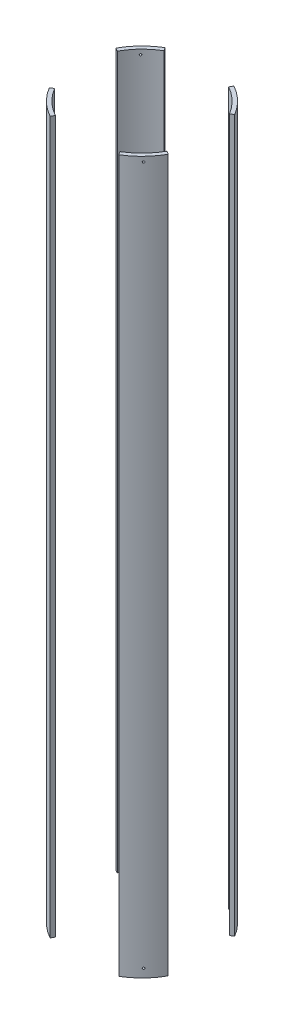
from build123d import *

# Parameters (mm, degrees)
SKETCH2_R               = 88.9
SKETCH2_R_2             = 83.82
BOSS_EXTRUDE1_DEPTH     = 467.94801
CUT_EXTRUDE1_DEPTH      = 468.94801
CUT_EXTRUDE1_DEPTH_BACK = 468.94801
SKETCH5_R               = 1.27
BOLT_HOLES_DEPTH        = 29.911624556
BOLT_PATTERN_COUNT      = 4


with BuildPart() as part:
    # Sketch2 → Boss-Extrude1 (new body, symmetric)
    with BuildSketch(Plane(origin=(0, 0, 0), x_dir=(1, 0, 0), z_dir=(0, 1, 0))):
        Circle(SKETCH2_R)
        Circle(SKETCH2_R_2, mode=Mode.SUBTRACT)
    extrude(amount=BOSS_EXTRUDE1_DEPTH, both=True)

    # Sketch3 → Cut-Extrude1 (cut, two sides)
    with BuildSketch(Plane(origin=(0, 0, 0), x_dir=(1, 0, 0), z_dir=(0, 1, 0))) as cut_extrude1_sk:
        Polygon((169.661755759, -94.300371224), (0, 0), (169.661755759, 101.677593364), align=None)
        Polygon((0, 0), (53.900027233, 96.974944394), (-58.116685864, 96.974944394), align=None)
        Polygon((-123.741299607, 68.777140945), (-123.741299607, -74.157652604), (0, 0), align=None)
        Polygon((-65.840936026, -118.45858783), (0, 0), (70.991745134, -118.45858783), align=None)
    extrude(amount=CUT_EXTRUDE1_DEPTH, mode=Mode.SUBTRACT)
    extrude(cut_extrude1_sk.sketch, amount=-CUT_EXTRUDE1_DEPTH_BACK, mode=Mode.SUBTRACT)

    # Sketch5 → Bolt holes (cut, through all)
    with BuildSketch(Plane(origin=(-56.309218645, 0, 58.175814955), x_dir=(-0.718540152, 0, -0.695485478), z_dir=(0.695485478, 0, -0.718540152))):
        with Locations((-0.02278764, 461.59801)):
            Circle(SKETCH5_R)
        with Locations((-0.02278764, -456.83551)):
            Circle(SKETCH5_R)
    bolt_holes = extrude(amount=-BOLT_HOLES_DEPTH, mode=Mode.SUBTRACT)

    # Bolt pattern: Bolt holes ×4 about axis
    bolt_pattern_axis = Axis((0, 467.94801, 0), (0, 1, 0))
    for i in range(1, BOLT_PATTERN_COUNT):
        add(bolt_holes.rotate(bolt_pattern_axis, i * 360 / BOLT_PATTERN_COUNT), mode=Mode.SUBTRACT)


solid = part.part
